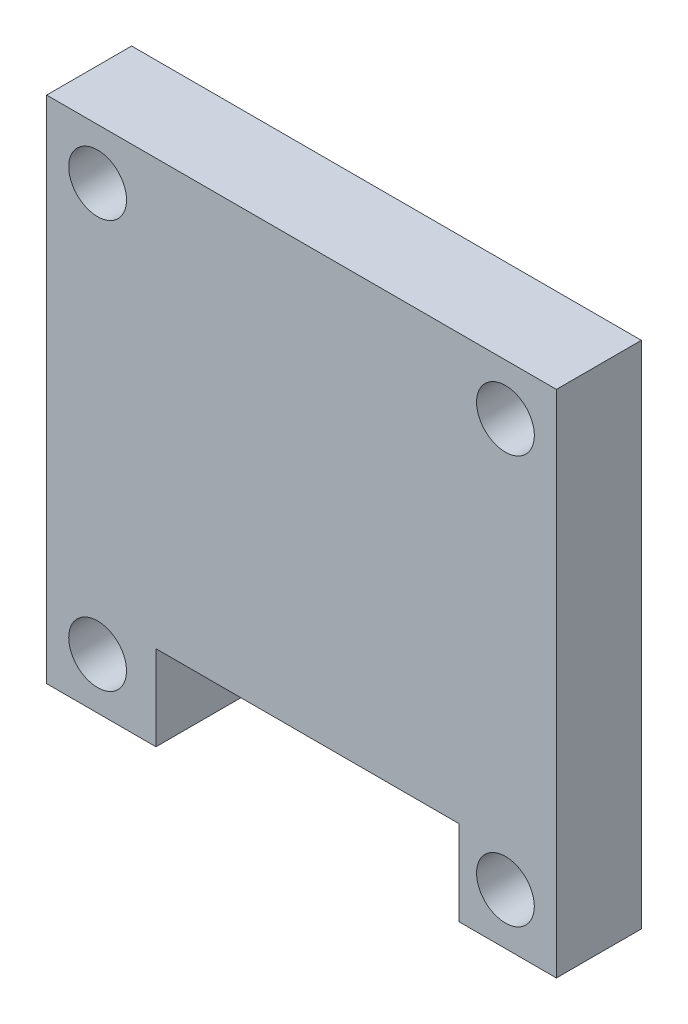
from build123d import *

# Parameters (mm, degrees)
SKETCH1_W           = 30
SKETCH1_H           = 30
SKETCH1_R           = 1.7
BOSS_EXTRUDE1_DEPTH = 5
SKETCH3_W           = 17.830647844
SKETCH3_H           = 5
CUT_EXTRUDE1_DEPTH  = 5


with BuildPart() as part:
    # Sketch1 → Boss-Extrude1 (new body)
    with BuildSketch(Plane.XY):
        with Locations((15, 15)):
            Rectangle(SKETCH1_W, SKETCH1_H)
        with Locations((3, 27)):
            Circle(SKETCH1_R, mode=Mode.SUBTRACT)
        with Locations((27, 27)):
            Circle(SKETCH1_R, mode=Mode.SUBTRACT)
        with Locations((27, 3)):
            Circle(SKETCH1_R, mode=Mode.SUBTRACT)
        with Locations((3, 3)):
            Circle(SKETCH1_R, mode=Mode.SUBTRACT)
    extrude(amount=BOSS_EXTRUDE1_DEPTH)

    # Sketch3 → Cut-Extrude1 (cut)
    with BuildSketch(Plane.XY.offset(5)):
        with Locations((15.350024265, 2.5)):
            Rectangle(SKETCH3_W, SKETCH3_H)
    extrude(amount=-CUT_EXTRUDE1_DEPTH, mode=Mode.SUBTRACT)


solid = part.part
